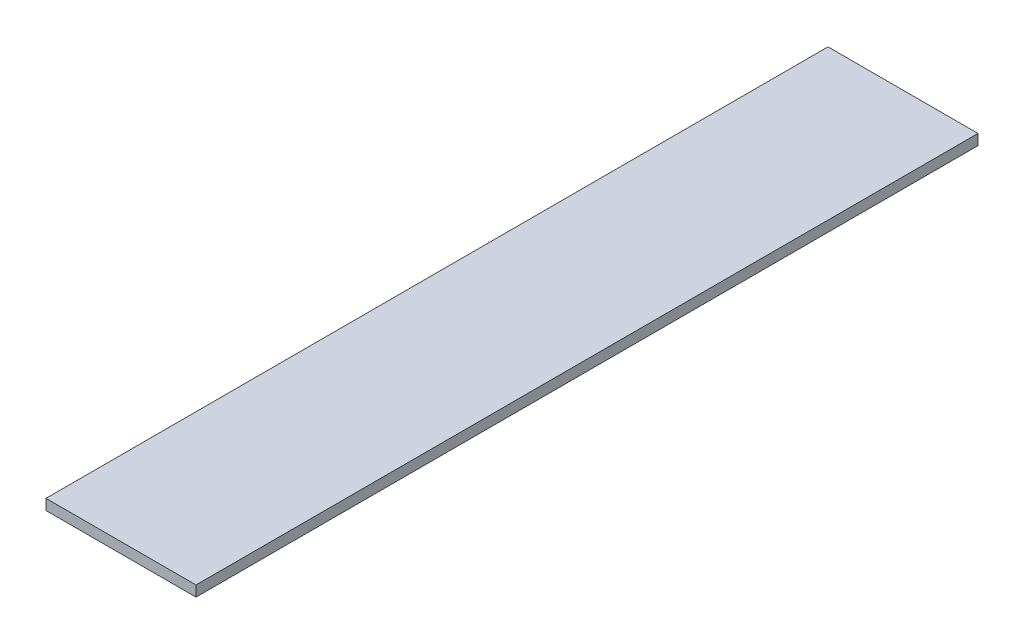
from build123d import *

# Parameters (mm, degrees)
SKETCH1_W           = 90
SKETCH1_H           = 469.2
BOSS_EXTRUDE1_DEPTH = 6.35


with BuildPart() as part:
    # Sketch1 → Boss-Extrude1 (new body)
    with BuildSketch(Plane(origin=(0, 0, 0), x_dir=(1, 0, 0), z_dir=(0, 1, 0))):
        with Locations((45, 234.6)):
            Rectangle(SKETCH1_W, SKETCH1_H)
    extrude(amount=BOSS_EXTRUDE1_DEPTH)


solid = part.part
